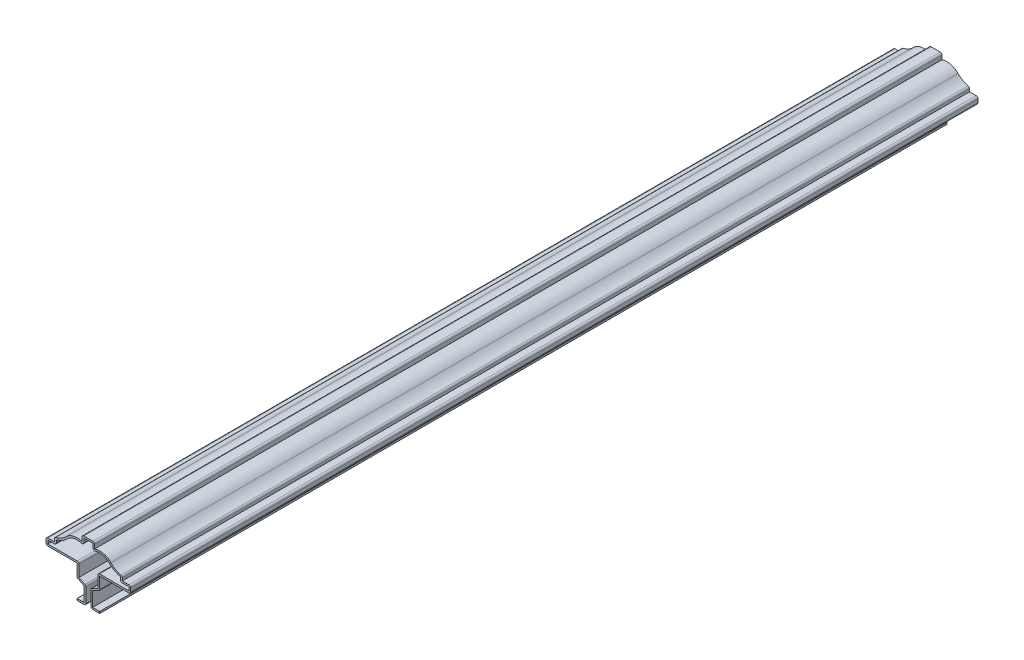
from build123d import *

# Parameters (mm, degrees)
EXTRUDE_THIN2_DEPTH = 476.25
FILLET1_R           = 1.016


with BuildPart() as part:
    # Sketch1 → Extrude-Thin2 (new body)
    with BuildSketch(Plane.XY):
        with BuildLine():
            Line((-6.35, 0), (-2.38125, 0))
            Line((-2.38125, 0), (-2.38125, 8.112125))
            Line((-2.38125, 8.112125), (-6.35, 10.0965))
            Line((-6.35, 10.0965), (-6.35, 17.24025))
            Line((-6.35, 17.24025), (-23.8125, 17.24025))
            Line((-23.8125, 17.24025), (-23.8125, 21.209))
            Line((-23.8125, 21.209), (-19.05, 21.209))
            Line((-19.05, 21.209), (-19.05, 23.59025))
            ThreePointArc((-19.05, 23.59025), (-15.568214533, 24.697581116), (-12.633740801, 26.874247409))
            ThreePointArc((-12.633740801, 26.874247409), (-8.42347359, 29.293600923), (-3.571875, 29.089609403))
            Line((-3.571875, 29.089609403), (-3.571875, 32.3215))
            Line((-3.571875, 32.3215), (3.571875, 32.3215))
            Line((3.571875, 32.3215), (3.571875, 29.089609403))
            ThreePointArc((3.571875, 29.089609403), (8.42347359, 29.293600923), (12.633740801, 26.874247409))
            ThreePointArc((12.633740801, 26.874247409), (15.568214533, 24.697581116), (19.05, 23.59025))
            Line((19.05, 23.59025), (19.05, 21.209))
            Line((19.05, 21.209), (23.8125, 21.209))
            Line((23.8125, 21.209), (23.8125, 17.24025))
            Line((23.8125, 17.24025), (6.35, 17.24025))
            Line((6.35, 17.24025), (6.35, 10.0965))
            Line((6.35, 10.0965), (2.38125, 8.112125))
            Line((2.38125, 8.112125), (2.38125, 0))
            Line((2.38125, 0), (6.35, 0))
            Line((6.35, 0), (6.35, -1.016))
            Line((6.35, -1.016), (1.36525, -1.016))
            Line((1.36525, -1.016), (1.36525, 8.740047533))
            Line((1.36525, 8.740047533), (5.334, 10.724422533))
            Line((5.334, 10.724422533), (5.334, 18.25625))
            Line((5.334, 18.25625), (22.7965, 18.25625))
            Line((22.7965, 18.25625), (22.7965, 20.193))
            Line((22.7965, 20.193), (18.034, 20.193))
            Line((18.034, 20.193), (18.034, 22.742528034))
            ThreePointArc((18.034, 22.742528034), (14.714811847, 24.002111564), (11.902541871, 26.168836802))
            ThreePointArc((11.902541871, 26.168836802), (7.461841431, 28.446841183), (2.555875, 27.529989099))
            Line((2.555875, 27.529989099), (2.555875, 31.3055))
            Line((2.555875, 31.3055), (-2.555875, 31.3055))
            Line((-2.555875, 31.3055), (-2.555875, 27.529989099))
            ThreePointArc((-2.555875, 27.529989099), (-7.461841431, 28.446841183), (-11.902541871, 26.168836802))
            ThreePointArc((-11.902541871, 26.168836802), (-14.714811847, 24.002111564), (-18.034, 22.742528034))
            Line((-18.034, 22.742528034), (-18.034, 20.193))
            Line((-18.034, 20.193), (-22.7965, 20.193))
            Line((-22.7965, 20.193), (-22.7965, 18.25625))
            Line((-22.7965, 18.25625), (-5.334, 18.25625))
            Line((-5.334, 18.25625), (-5.334, 10.724422533))
            Line((-5.334, 10.724422533), (-1.36525, 8.740047533))
            Line((-1.36525, 8.740047533), (-1.36525, -1.016))
            Line((-1.36525, -1.016), (-6.35, -1.016))
            Line((-6.35, -1.016), (-6.35, 0))
        make_face()
    extrude(amount=-EXTRUDE_THIN2_DEPTH)

    # Fillet1
    fillet1_edges = [part.edges().sort_by_distance(p)[0] for p in [
        (-6.35, 10.0965, -238.125),
        (-23.8125, 17.24025, -238.125),
        (-23.8125, 21.209, -238.125),
        (-19.05, 23.59025, -238.125),
        (-3.571875, 32.3215, -238.125),
        (3.571875, 32.3215, -238.125),
        (19.05, 23.59025, -238.125),
        (23.8125, 21.209, -238.125),
        (23.8125, 17.24025, -238.125),
        (6.35, 10.0965, -238.125),
        (1.36525, -1.016, -238.125),
        (1.36525, 8.740047533, -238.125),
        (5.334, 18.25625, -238.125),
        (18.034, 20.193, -238.125),
        (2.555875, 27.529989099, -238.125),
        (-2.555875, 27.529989099, -238.125),
        (-18.034, 20.193, -238.125),
        (-5.334, 18.25625, -238.125),
        (-1.36525, 8.740047533, -238.125),
        (-1.36525, -1.016, -238.125),
    ]]
    fillet(fillet1_edges, radius=FILLET1_R)


solid = part.part
